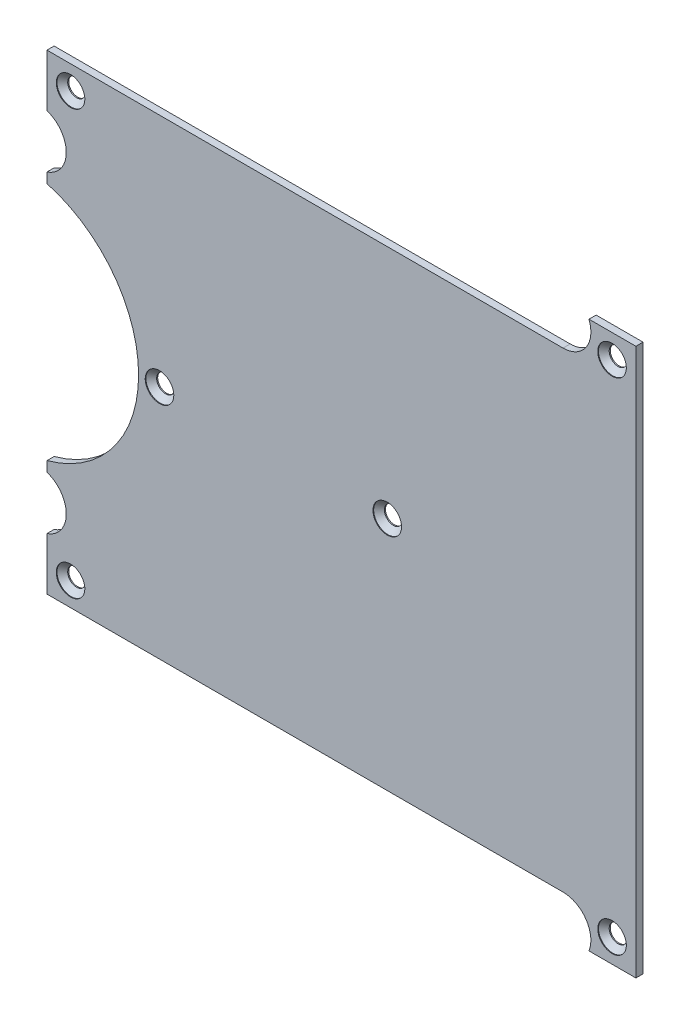
from build123d import *

# Parameters (mm, degrees)
SKETCH1_R                                      = 1.25
SHAPE_DEPTH                                    = 1
CSK_FOR_M2_FLAT_HEAD_MACHINE_SCREW1_AT_2_COUNT = 2
CSK_FOR_M2_FLAT_HEAD_MACHINE_SCREW1_AT_2_PITCH = 76.001699467
CSK_FOR_M2_FLAT_HEAD_MACHINE_SCREW1_AT_3_COUNT = 2
CSK_FOR_M2_FLAT_HEAD_MACHINE_SCREW1_AT_3_PITCH = 99.656702343
CSK_FOR_M2_FLAT_HEAD_MACHINE_SCREW1_AT_4_COUNT = 2
CSK_FOR_M2_FLAT_HEAD_MACHINE_SCREW1_AT_4_PITCH = 59.36
CSK_FOR_M2_FLAT_HEAD_MACHINE_SCREW1_AT_5_COUNT = 2
CSK_FOR_M2_FLAT_HEAD_MACHINE_SCREW1_AT_5_PITCH = 32.187410971
CSK_FOR_M2_FLAT_HEAD_MACHINE_SCREW1_AT_6_COUNT = 2
CSK_FOR_M2_FLAT_HEAD_MACHINE_SCREW1_AT_6_PITCH = 53.357546763


with BuildPart() as part:
    # Sketch1 → Shape (new body)
    with BuildSketch(Plane.XY):
        with BuildLine():
            Line((10.2, -38.3), (10.2, 38.3))
            Line((10.2, 38.3), (3.632299547, 38.3))
            ThreePointArc((3.632299547, 38.3), (3.220869448, 34.680909279), (0, 32.98))
            Line((0, 32.98), (-72.252025159, 32.98))
            Line((-72.252025159, 32.98), (-72.252025159, 25.630795063))
            ThreePointArc((-72.252025159, 25.630795063), (-69.552025159, 21.92), (-72.252025159, 18.209204937))
            Line((-72.252025159, 18.209204937), (-72.252025159, 16.789136368))
            ThreePointArc((-72.252025159, 16.789136368), (-59.422025159, 0), (-72.252025159, -16.789136368))
            Line((-72.252025159, -16.789136368), (-72.252025159, -18.209204937))
            ThreePointArc((-72.252025159, -18.209204937), (-69.552025159, -21.92), (-72.252025159, -25.630795063))
            Line((-72.252025159, -25.630795063), (-72.252025159, -32.98))
            Line((-72.252025159, -32.98), (0, -32.98))
            ThreePointArc((0, -32.98), (3.220869448, -34.680909279), (3.632299547, -38.3))
            Line((3.632299547, -38.3), (10.2, -38.3))
        make_face()
        with Locations((-68.952025159, 29.68)):
            Circle(SKETCH1_R, mode=Mode.SUBTRACT)
        with Locations((6.863249831, 35)):
            Circle(SKETCH1_R, mode=Mode.SUBTRACT)
        with Locations((6.863249831, -35)):
            Circle(SKETCH1_R, mode=Mode.SUBTRACT)
        with Locations((-68.952025159, -29.68)):
            Circle(SKETCH1_R, mode=Mode.SUBTRACT)
        with Locations((-56.497025159, 0)):
            Circle(SKETCH1_R, mode=Mode.SUBTRACT)
        with Locations((-24.61101258, 0)):
            Circle(SKETCH1_R, mode=Mode.SUBTRACT)
    extrude(amount=SHAPE_DEPTH)

    # Sketch3 → CSK for M2 Flat Head Machine Screw1 (revolve, cut)
    with BuildSketch(Plane(origin=(-68.952025159, 29.68, 1), x_dir=(0, -1, 0), z_dir=(1, 0, 0))):
        Polygon((0, 0), (0, 1), (1, 1), (1, 1.1), (2, 0.1), (2, 0), align=None)
    csk_for_m2_flat_head_machine_screw1 = revolve(axis=Axis((-68.952025159, 29.68, 7.35), (0, 0, -1)), mode=Mode.SUBTRACT)

    # CSK for M2 Flat Head Machine Screw1 at 2: CSK for M2 Flat Head Machine Screw1 ×2
    with Locations(*[Vector(0.997547101, 0.069998435, 0) * (i * CSK_FOR_M2_FLAT_HEAD_MACHINE_SCREW1_AT_2_PITCH) for i in range(1, CSK_FOR_M2_FLAT_HEAD_MACHINE_SCREW1_AT_2_COUNT)]):
        add(csk_for_m2_flat_head_machine_screw1, mode=Mode.SUBTRACT)

    # CSK for M2 Flat Head Machine Screw1 at 3: CSK for M2 Flat Head Machine Screw1 ×2
    with Locations(*[Vector(0.760764436, -0.649028098, 0) * (i * CSK_FOR_M2_FLAT_HEAD_MACHINE_SCREW1_AT_3_PITCH) for i in range(1, CSK_FOR_M2_FLAT_HEAD_MACHINE_SCREW1_AT_3_COUNT)]):
        add(csk_for_m2_flat_head_machine_screw1, mode=Mode.SUBTRACT)

    # CSK for M2 Flat Head Machine Screw1 at 4: CSK for M2 Flat Head Machine Screw1 ×2
    with Locations(*[(0, -i * CSK_FOR_M2_FLAT_HEAD_MACHINE_SCREW1_AT_4_PITCH, 0) for i in range(1, CSK_FOR_M2_FLAT_HEAD_MACHINE_SCREW1_AT_4_COUNT)]):
        add(csk_for_m2_flat_head_machine_screw1, mode=Mode.SUBTRACT)

    # CSK for M2 Flat Head Machine Screw1 at 5: CSK for M2 Flat Head Machine Screw1 ×2
    with Locations(*[Vector(0.386952527, -0.922099638, 0) * (i * CSK_FOR_M2_FLAT_HEAD_MACHINE_SCREW1_AT_5_PITCH) for i in range(1, CSK_FOR_M2_FLAT_HEAD_MACHINE_SCREW1_AT_5_COUNT)]):
        add(csk_for_m2_flat_head_machine_screw1, mode=Mode.SUBTRACT)

    # CSK for M2 Flat Head Machine Screw1 at 6: CSK for M2 Flat Head Machine Screw1 ×2
    with Locations(*[Vector(0.831016703, -0.556247463, 0) * (i * CSK_FOR_M2_FLAT_HEAD_MACHINE_SCREW1_AT_6_PITCH) for i in range(1, CSK_FOR_M2_FLAT_HEAD_MACHINE_SCREW1_AT_6_COUNT)]):
        add(csk_for_m2_flat_head_machine_screw1, mode=Mode.SUBTRACT)


solid = part.part
